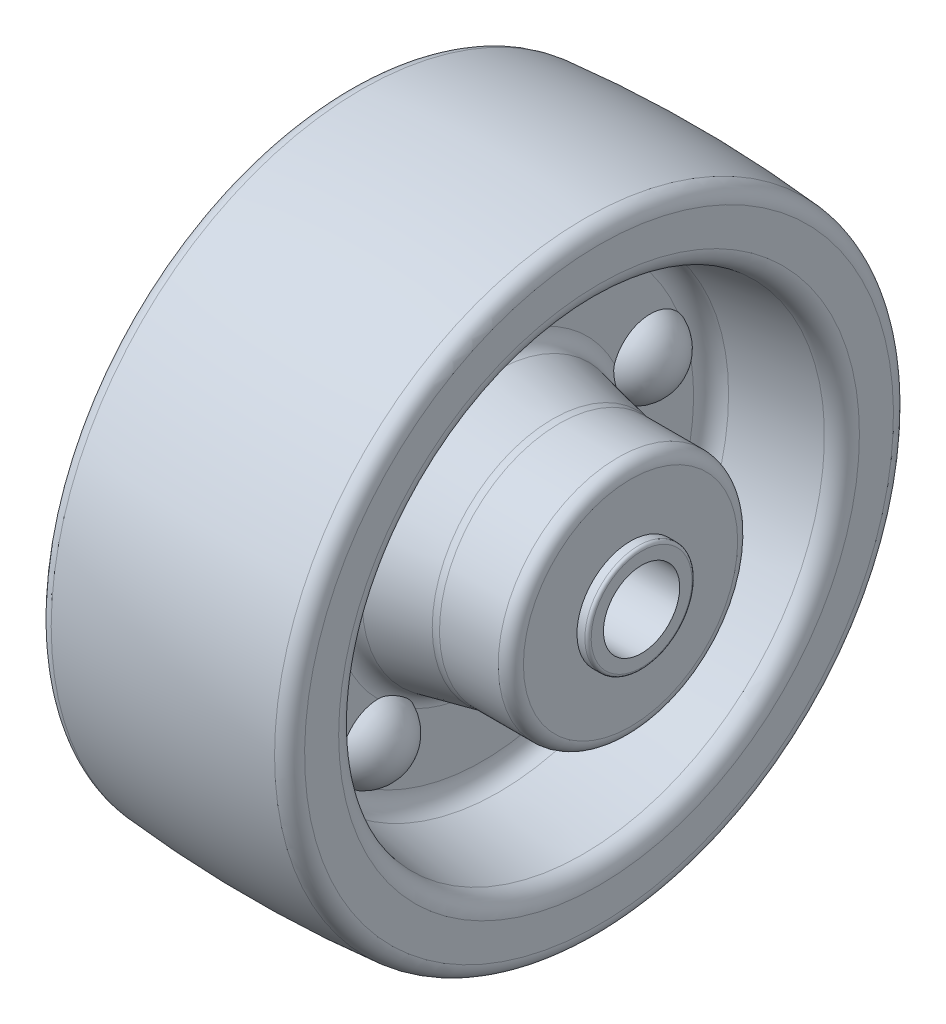
from build123d import *

# Parameters (mm, degrees)
FILLET1_R         = 2.5
FILLET2_R         = 3
FILLET3_R         = 5
FILLET4_R         = 2
FILLET5_R         = 0.5
CIRPATTERN1_COUNT = 5
CIRPATTERN1_ANGLE = 288


with BuildPart() as part:
    # Sketch1 → Revolve1 (revolve)
    with BuildSketch(Plane.XY):
        with BuildLine():
            Line((-20, 38.713), (-20, 48.997487421))
            ThreePointArc((-20, 48.997487421), (0, 50), (20, 48.997487421))
            Line((20, 48.997487421), (20, 38.713))
            Line((20, 38.713), (1.5, 36.112994558))
            Line((1.5, 36.112994558), (1.5, 21.477005442))
            Line((1.5, 21.477005442), (13.153394384, 19))
            Line((13.153394384, 19), (25, 19))
            Line((25, 19), (25, 8.5))
            Line((25, 8.5), (26.751, 8.5))
            Line((26.751, 8.5), (26.751, 6.05))
            Line((26.751, 6.05), (-26.751, 6.05))
            Line((-26.751, 6.05), (-26.751, 8.5))
            Line((-26.751, 8.5), (-25, 8.5))
            Line((-25, 8.5), (-25, 19))
            Line((-25, 19), (-13.153394384, 19))
            Line((-13.153394384, 19), (-1.5, 21.477005442))
            Line((-1.5, 21.477005442), (-1.5, 36.112994558))
            Line((-1.5, 36.112994558), (-20, 38.713))
        make_face()
    revolve(axis=Axis((0, 0, 0), (-1, 0, 0)))

    # Fillet1
    fillet1_edges = [part.edges().sort_by_distance(p)[0] for p in [
        (1.5, -21.477005442, 0),
        (-1.5, -21.477005442, 0),
        (20, -48.997487421, 0),
        (-20, -48.997487421, 0),
    ]]
    fillet(fillet1_edges, radius=FILLET1_R)

    # Fillet2
    fillet2_edges = [part.edges().sort_by_distance(p)[0] for p in [
        (-1.5, -36.112994558, 0),
        (1.5, -36.112994558, 0),
        (20, -38.713, 0),
        (-20, -38.713, 0),
    ]]
    fillet(fillet2_edges, radius=FILLET2_R)

    # Fillet3
    fillet3_edges = [part.edges().sort_by_distance(p)[0] for p in [
        (13.153394384, -19, 0),
        (-13.153394384, -19, 0),
    ]]
    fillet(fillet3_edges, radius=FILLET3_R)

    # Fillet4
    fillet4_edges = [part.edges().sort_by_distance(p)[0] for p in [
        (-25, -19, 0),
        (25, -19, 0),
    ]]
    fillet(fillet4_edges, radius=FILLET4_R)

    # Fillet5
    fillet5_edges = [part.edges().sort_by_distance(p)[0] for p in [
        (26.751, -8.5, 0),
        (-26.751, -8.5, 0),
    ]]
    fillet(fillet5_edges, radius=FILLET5_R)

    # Sketch2 → Revolve2 (revolve)
    with BuildSketch(Plane.XY):
        with BuildLine():
            Line((-1.5, 28), (-5.5, 28))
            ThreePointArc((-5.5, 28), (-4.408326913, 31.605551275), (-1.5, 34))
            Line((-1.5, 34), (-1.5, 28))
        make_face()
        with BuildLine():
            Line((1.5, 28), (1.5, 34))
            ThreePointArc((1.5, 34), (4.408326913, 31.605551275), (5.5, 28))
            Line((5.5, 28), (1.5, 28))
        make_face()
    revolve2 = revolve(axis=Axis((-1.5, 28, 0), (-1, 0, 0)))

    # CirPattern1: Revolve2 ×5 about axis
    cirpattern1_axis = Axis((-88.99, 0, 0), (1, 0, 0))
    for i in range(1, CIRPATTERN1_COUNT):
        add(revolve2.rotate(cirpattern1_axis, i * CIRPATTERN1_ANGLE / (CIRPATTERN1_COUNT - 1)))


solid = part.part
